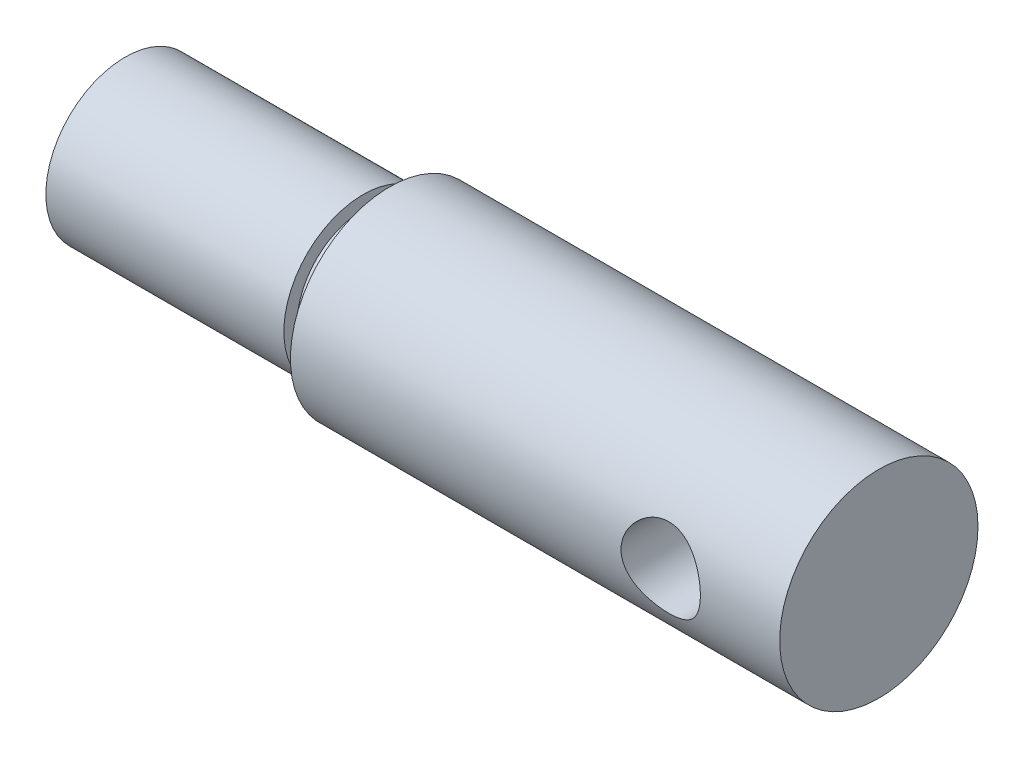
from build123d import *

# Parameters (mm, degrees)
SKETCH2_R               = 3
CUT_EXTRUDE1_DEPTH      = 8.5
CUT_EXTRUDE1_DEPTH_BACK = 8.5
DOME1_FACE_RADIUS       = 6
DOME1_HEIGHT            = 2


with BuildPart() as part:
    # Sketch1 → Revolve1 (revolve)
    with BuildSketch(Plane.XY):
        Polygon((57, 0), (0, 0), (0, 6), (18, 6), (18, 5), (20, 5), (20, 7.5), (57, 7.5), align=None)
    revolve(axis=Axis((57, 0, 0), (-1, 0, 0)))

    # Sketch2 → Cut-Extrude1 (cut, two sides)
    with BuildSketch(Plane.XY) as cut_extrude1_sk:
        with Locations((48, 0)):
            Circle(SKETCH2_R)
    extrude(amount=CUT_EXTRUDE1_DEPTH, mode=Mode.SUBTRACT)
    extrude(cut_extrude1_sk.sketch, amount=-CUT_EXTRUDE1_DEPTH_BACK, mode=Mode.SUBTRACT)

    # Dome1: a dome of height H over a round flat face of radius A is a cap of a sphere of radius (A * A + H * H) / (2 * H)
    dome1_r = (DOME1_FACE_RADIUS * DOME1_FACE_RADIUS + DOME1_HEIGHT * DOME1_HEIGHT) / (2 * DOME1_HEIGHT)
    dome1_base = Plane((0, 0, 0), z_dir=(-1, 0, 0))
    with Locations(dome1_base.offset(DOME1_HEIGHT - dome1_r)):
        dome1_ball = Sphere(dome1_r, mode=Mode.PRIVATE)
    add(split(dome1_ball, bisect_by=dome1_base, keep=Keep.TOP, mode=Mode.PRIVATE))


solid = part.part
